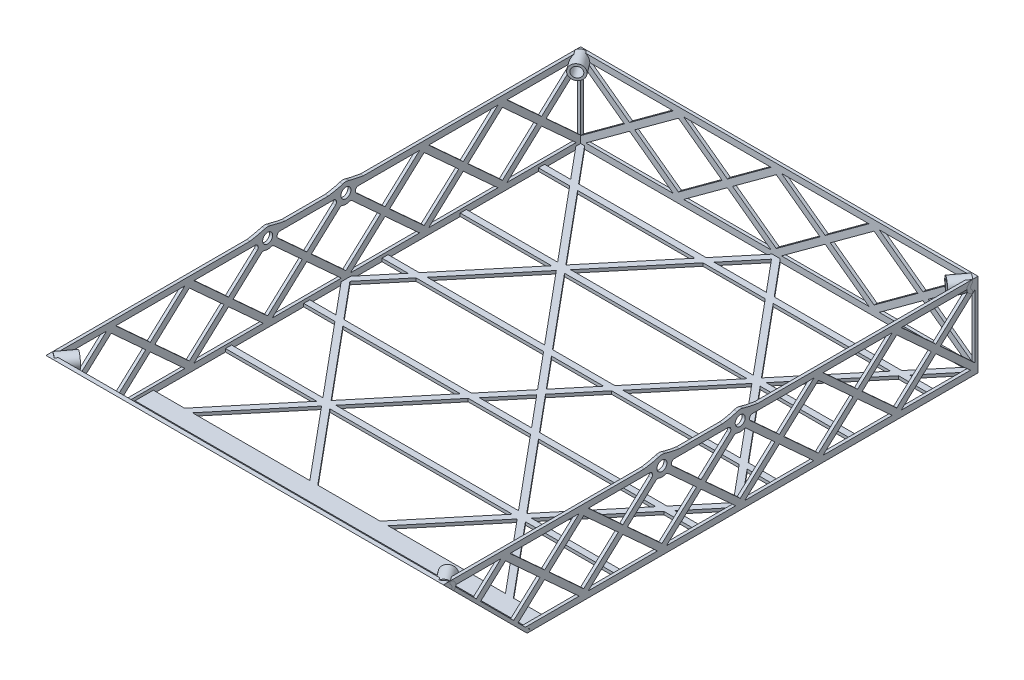
from build123d import *

# Parameters (mm, degrees)
SKETCH1_W                = 206.375
SKETCH1_H                = 233.045
BOSS_EXTRUDE3_DEPTH      = 1.5875
SKETCH2_W                = 206.375
SKETCH2_H                = 247.015
SKETCH2_W_2              = 203.2
SKETCH2_H_2              = 243.84
BOSS_EXTRUDE4_DEPTH      = 41.91
CUT_EXTRUDE3_DEPTH       = 1
CUT_EXTRUDE3_DEPTH_BACK  = 207.375
CUT_EXTRUDE1_DEPTH       = 1
CUT_EXTRUDE1_DEPTH_BACK  = 248.015
BOSS_EXTRUDE5_DEPTH      = 206.375
CUT_EXTRUDE4_DEPTH       = 6.35
CUT_EXTRUDE8_DEPTH       = 1
CUT_EXTRUDE8_DEPTH_BACK  = 207.375
BOSS_EXTRUDE8_DEPTH      = 1.5875
BOSS_EXTRUDE9_DEPTH      = 1.5875
SKETCH18_R               = 5.08
SKETCH18_R_2             = 2.6
BOSS_EXTRUDE10_DEPTH     = 1.5875
SKETCH18_3_R             = 2.6
BOSS_EXTRUDE11_DEPTH     = 1.5875
SKETCH18_4_R             = 2.6
CUT_EXTRUDE9_DEPTH       = 1.5875
SKETCH19_R               = 5.08
SKETCH19_R_2             = 2.6
BOSS_EXTRUDE12_DEPTH     = 1.5875
SKETCH19_4_R             = 2.6
CUT_EXTRUDE10_DEPTH      = 1.5875
FILLET1_R                = 1.5
SKETCH22_R               = 3.81
SKETCH22_R_2             = 2.6
BOSS_EXTRUDE17_DEPTH     = 9.525
CUT_EXTRUDE11_DEPTH      = 2.9050001
CUT_EXTRUDE11_DEPTH_BACK = 44.4975001
CUT_EXTRUDE12_DEPTH      = 228.106352508
CUT_EXTRUDE12_DEPTH_BACK = 2.34703856


with BuildPart() as part:
    # Sketch1 → Boss-Extrude3 (new body)
    with BuildSketch(Plane(origin=(0, 0, 0), x_dir=(1, 0, 0), z_dir=(0, 1, 0))):
        with Locations((0, 6.985)):
            Rectangle(SKETCH1_W, SKETCH1_H)
        Polygon((-101.6, -62.5475), (-54.18937856, -62.5475), (-85.410211893, -100.0125), (-101.6, -100.0125), align=None, mode=Mode.SUBTRACT)
        Polygon((-81.277288107, -100.0125), (-50.8, -63.439754272), (-20.322711893, -100.0125), align=None, mode=Mode.SUBTRACT)
        Polygon((-16.189788107, -100.0125), (-47.41062144, -62.5475), (47.41062144, -62.5475), (16.189788107, -100.0125), align=None, mode=Mode.SUBTRACT)
        Polygon((-85.410211893, -21.9075), (-54.18937856, -59.3725), (-101.6, -59.3725), (-101.6, -21.9075), align=None, mode=Mode.SUBTRACT)
        Polygon((-50.8, -58.480245728), (-81.277288107, -21.9075), (-20.322711893, -21.9075), align=None, mode=Mode.SUBTRACT)
        Polygon((-101.6, -18.7325), (-101.6, -2.479754272), (-88.056045227, -18.7325), align=None, mode=Mode.SUBTRACT)
        Polygon((-101.6, 18.7325), (-88.056045227, 18.7325), (-101.6, 2.479754272), align=None, mode=Mode.SUBTRACT)
        Polygon((-47.41062144, -59.3725), (-16.189788107, -21.9075), (16.189788107, -21.9075), (47.41062144, -59.3725), align=None, mode=Mode.SUBTRACT)
        Polygon((13.543954773, -18.7325), (-13.543954773, -18.7325), (0, -2.479754272), align=None, mode=Mode.SUBTRACT)
        Polygon((-13.543954773, 18.7325), (13.543954773, 18.7325), (0, 2.479754272), align=None, mode=Mode.SUBTRACT)
        Polygon((50.8, -63.439754272), (81.277288107, -100.0125), (20.322711893, -100.0125), align=None, mode=Mode.SUBTRACT)
        Polygon((85.410211893, -100.0125), (54.18937856, -62.5475), (101.6, -62.5475), (101.6, -100.0125), align=None, mode=Mode.SUBTRACT)
        Polygon((50.8, -58.480245728), (20.322711893, -21.9075), (81.277288107, -21.9075), align=None, mode=Mode.SUBTRACT)
        Polygon((17.67687856, -18.7325), (2.066461893, 0), (17.67687856, 18.7325), (83.92312144, 18.7325), (99.533538107, 0), (83.92312144, -18.7325), align=None, mode=Mode.SUBTRACT)
        Polygon((54.18937856, -59.3725), (85.410211893, -21.9075), (101.6, -21.9075), (101.6, -59.3725), align=None, mode=Mode.SUBTRACT)
        Polygon((101.6, -18.7325), (88.056045227, -18.7325), (101.6, -2.479754272), align=None, mode=Mode.SUBTRACT)
        Polygon((101.6, 2.479754272), (88.056045227, 18.7325), (101.6, 18.7325), align=None, mode=Mode.SUBTRACT)
        Polygon((-99.533538107, 0), (-83.92312144, 18.7325), (-17.67687856, 18.7325), (-2.066461893, 0), (-17.67687856, -18.7325), (-83.92312144, -18.7325), align=None, mode=Mode.SUBTRACT)
        Polygon((-81.277288107, 21.9075), (-50.8, 58.480245728), (-20.322711893, 21.9075), align=None, mode=Mode.SUBTRACT)
        Polygon((-54.18937856, 59.3725), (-85.410211893, 21.9075), (-101.6, 21.9075), (-101.6, 59.3725), align=None, mode=Mode.SUBTRACT)
        Polygon((16.189788107, 21.9075), (-16.189788107, 21.9075), (-47.41062144, 59.3725), (47.41062144, 59.3725), align=None, mode=Mode.SUBTRACT)
        Polygon((-85.410211893, 100.0125), (-54.18937856, 62.5475), (-101.6, 62.5475), (-101.6, 100.0125), align=None, mode=Mode.SUBTRACT)
        Polygon((-20.322711893, 100.0125), (-50.8, 63.439754272), (-81.277288107, 100.0125), align=None, mode=Mode.SUBTRACT)
        Polygon((-101.6, 103.1875), (-101.6, 119.440245728), (-88.056045227, 103.1875), align=None, mode=Mode.SUBTRACT)
        Polygon((-17.67687856, 103.1875), (-83.92312144, 103.1875), (-99.533538107, 121.92), (-2.066461893, 121.92), align=None, mode=Mode.SUBTRACT)
        Polygon((47.41062144, 62.5475), (-47.41062144, 62.5475), (-16.189788107, 100.0125), (16.189788107, 100.0125), align=None, mode=Mode.SUBTRACT)
        Polygon((0, 119.440245728), (13.543954773, 103.1875), (-13.543954773, 103.1875), align=None, mode=Mode.SUBTRACT)
        Polygon((50.8, 58.480245728), (81.277288107, 21.9075), (20.322711893, 21.9075), align=None, mode=Mode.SUBTRACT)
        Polygon((101.6, 21.9075), (85.410211893, 21.9075), (54.18937856, 59.3725), (101.6, 59.3725), align=None, mode=Mode.SUBTRACT)
        Polygon((81.277288107, 100.0125), (50.8, 63.439754272), (20.322711893, 100.0125), align=None, mode=Mode.SUBTRACT)
        Polygon((83.92312144, 103.1875), (17.67687856, 103.1875), (2.066461893, 121.92), (99.533538107, 121.92), align=None, mode=Mode.SUBTRACT)
        Polygon((101.6, 100.0125), (101.6, 62.5475), (54.18937856, 62.5475), (85.410211893, 100.0125), align=None, mode=Mode.SUBTRACT)
        Polygon((101.6, 119.440245728), (101.6, 103.1875), (88.056045227, 103.1875), align=None, mode=Mode.SUBTRACT)
    extrude(amount=BOSS_EXTRUDE3_DEPTH)

    # Sketch2 → Boss-Extrude4 (add)
    with BuildSketch(Plane(origin=(0, 1.5875, 0), x_dir=(1, 0, 0), z_dir=(0, 1, 0))):
        Rectangle(SKETCH2_W, SKETCH2_H)
        Rectangle(SKETCH2_W_2, SKETCH2_H_2, mode=Mode.SUBTRACT)
    extrude(amount=BOSS_EXTRUDE4_DEPTH)

    # Sketch4 → Cut-Extrude3 (cut, two sides)
    with BuildSketch(Plane.ZY.offset(103.1875)) as cut_extrude3_sk:
        Polygon((-103.952969238, 21.74875), (-121.92, 38.171739056), (-121.92, 5.325760944), align=None)
        Polygon((-83.632969238, 40.3225), (-119.567030762, 40.3225), (-101.6, 23.899510944), align=None)
        Polygon((-83.632969238, 3.175), (-101.6, 19.597989056), (-119.567030762, 3.175), align=None)
        Polygon((-42.992969238, 40.3225), (-78.927030762, 40.3225), (-60.96, 23.899510944), align=None)
        Polygon((-81.28, 38.171739056), (-99.247030762, 21.74875), (-81.28, 5.325760944), (-63.312969238, 21.74875), align=None)
        Polygon((-60.96, 19.597989056), (-78.927030762, 3.175), (-42.992969238, 3.175), align=None)
        Polygon((-2.352969238, 40.3225), (-38.287030762, 40.3225), (-20.32, 23.899510944), align=None)
        Polygon((-40.64, 38.171739056), (-58.607030762, 21.74875), (-40.64, 5.325760944), (-22.672969238, 21.74875), align=None)
        Polygon((-20.32, 19.597989056), (-38.287030762, 3.175), (-2.352969238, 3.175), align=None)
        Polygon((38.287030762, 40.3225), (2.352969238, 40.3225), (20.32, 23.899510944), align=None)
        Polygon((0, 38.171739056), (-17.967030762, 21.74875), (0, 5.325760944), (17.967030762, 21.74875), align=None)
        Polygon((20.32, 19.597989056), (2.352969238, 3.175), (38.287030762, 3.175), align=None)
        Polygon((78.927030762, 40.3225), (42.992969238, 40.3225), (60.96, 23.899510944), align=None)
        Polygon((40.64, 38.171739056), (22.672969238, 21.74875), (40.64, 5.325760944), (58.607030762, 21.74875), align=None)
        Polygon((60.96, 19.597989056), (42.992969238, 3.175), (78.927030762, 3.175), align=None)
        Polygon((119.567030762, 40.3225), (83.632969238, 40.3225), (101.6, 23.899510944), align=None)
        Polygon((81.28, 38.171739056), (63.312969238, 21.74875), (81.28, 5.325760944), (99.247030762, 21.74875), align=None)
        Polygon((101.6, 19.597989056), (83.632969238, 3.175), (119.567030762, 3.175), align=None)
        Polygon((121.92, 5.325760944), (121.92, 38.171739056), (103.952969238, 21.74875), align=None)
    extrude(amount=CUT_EXTRUDE3_DEPTH, mode=Mode.SUBTRACT)
    extrude(cut_extrude3_sk.sketch, amount=-CUT_EXTRUDE3_DEPTH_BACK, mode=Mode.SUBTRACT)

    # Sketch3 → Cut-Extrude1 (cut, two sides)
    with BuildSketch(Plane.XY.offset(123.5075)) as cut_extrude1_sk:
        Polygon((76.2, 23.715409792), (98.910550711, 40.3225), (53.489449289, 40.3225), align=None)
        Polygon((101.6, 5.141659792), (101.6, 38.355840208), (78.889449289, 21.74875), align=None)
        Polygon((25.4, 23.715409792), (48.110550711, 40.3225), (2.689449289, 40.3225), align=None)
        Polygon((50.8, 5.141659792), (73.510550711, 21.74875), (50.8, 38.355840208), (28.089449289, 21.74875), align=None)
        Polygon((98.910550711, 3.175), (76.2, 19.782090208), (53.489449289, 3.175), align=None)
        Polygon((2.689449289, 3.175), (48.110550711, 3.175), (25.4, 19.782090208), align=None)
        Polygon((-25.4, 23.715409792), (-2.689449289, 40.3225), (-48.110550711, 40.3225), align=None)
        Polygon((0, 5.141659792), (22.710550711, 21.74875), (0, 38.355840208), (-22.710550711, 21.74875), align=None)
        Polygon((-48.110550711, 3.175), (-2.689449289, 3.175), (-25.4, 19.782090208), align=None)
        Polygon((-76.2, 23.715409792), (-53.489449289, 40.3225), (-98.910550711, 40.3225), align=None)
        Polygon((-50.8, 5.141659792), (-28.089449289, 21.74875), (-50.8, 38.355840208), (-73.510550711, 21.74875), align=None)
        Polygon((-98.910550711, 3.175), (-53.489449289, 3.175), (-76.2, 19.782090208), align=None)
        Polygon((-78.889449289, 21.74875), (-101.6, 38.355840208), (-101.6, 5.141659792), align=None)
    extrude(amount=CUT_EXTRUDE1_DEPTH, mode=Mode.SUBTRACT)
    extrude(cut_extrude1_sk.sketch, amount=-CUT_EXTRUDE1_DEPTH_BACK, mode=Mode.SUBTRACT)

    # Sketch7 → Boss-Extrude5 (add)
    with BuildSketch(Plane(origin=(103.1875, 0, 0), x_dir=(0, 0, -1), z_dir=(1, 0, 0))):
        Polygon((-110.674383618, 0), (-108.429319587, 0), (-115.968409784, 7.539090197), (-151.926819587, 43.4975), (-154.171883618, 43.4975), align=None)
    extrude(amount=-BOSS_EXTRUDE5_DEPTH)

    # Sketch8 → Cut-Extrude4 (cut)
    with BuildSketch(Plane(origin=(0, -55.337191809, 55.337191809), x_dir=(1, 0, 0), z_dir=(0, -0.707106781, 0.707106781))):
        Polygon((-76.770919233, 136.598361589), (-98.250955767, 136.598361589), (-87.5109375, 114.266316603), align=None)
        Polygon((-89.272481733, 110.603484374), (-100.0125, 132.93552936), (-100.0125, 88.271439388), align=None)
        Polygon((-76.770919233, 84.60860716), (-87.5109375, 106.940652146), (-98.250955767, 84.60860716), align=None)
        Polygon((-75.009375, 132.93552936), (-85.749393267, 110.603484374), (-75.009375, 88.271439388), (-64.269356733, 110.603484374), align=None)
        Polygon((-62.5078125, 106.940652146), (-73.247830767, 84.60860716), (-51.767794233, 84.60860716), align=None)
        Polygon((-50.00625, 132.93552936), (-60.746268267, 110.603484374), (-50.00625, 88.271439388), (-39.266231733, 110.603484374), align=None)
        Polygon((-37.5046875, 106.940652146), (-48.244705767, 84.60860716), (-26.764669233, 84.60860716), align=None)
        Polygon((-25.003125, 132.93552936), (-35.743143267, 110.603484374), (-25.003125, 88.271439388), (-14.263106733, 110.603484374), align=None)
        Polygon((-12.5015625, 106.940652146), (-23.241580767, 84.60860716), (-1.761544233, 84.60860716), align=None)
        Polygon((0, 132.93552936), (-10.740018267, 110.603484374), (0, 88.271439388), (10.740018267, 110.603484374), align=None)
        Polygon((12.5015625, 106.940652146), (1.761544233, 84.60860716), (23.241580767, 84.60860716), align=None)
        Polygon((25.003125, 132.93552936), (14.263106733, 110.603484374), (25.003125, 88.271439388), (35.743143267, 110.603484374), align=None)
        Polygon((37.5046875, 106.940652146), (26.764669233, 84.60860716), (48.244705767, 84.60860716), align=None)
        Polygon((50.00625, 132.93552936), (39.266231733, 110.603484374), (50.00625, 88.271439388), (60.746268267, 110.603484374), align=None)
        Polygon((62.5078125, 106.940652146), (51.767794233, 84.60860716), (73.247830767, 84.60860716), align=None)
        Polygon((75.009375, 132.93552936), (64.269356733, 110.603484374), (75.009375, 88.271439388), (85.749393267, 110.603484374), align=None)
        Polygon((87.5109375, 106.940652146), (76.770919233, 84.60860716), (98.250955767, 84.60860716), align=None)
        Polygon((100.0125, 132.93552936), (89.272481733, 110.603484374), (100.0125, 88.271439388), align=None)
        Polygon((98.250955767, 136.598361589), (76.770919233, 136.598361589), (87.5109375, 114.266316603), align=None)
        Polygon((73.247830767, 136.598361589), (51.767794233, 136.598361589), (62.5078125, 114.266316603), align=None)
        Polygon((48.244705767, 136.598361589), (26.764669233, 136.598361589), (37.5046875, 114.266316603), align=None)
        Polygon((23.241580767, 136.598361589), (1.761544233, 136.598361589), (12.5015625, 114.266316603), align=None)
        Polygon((-1.761544233, 136.598361589), (-23.241580767, 136.598361589), (-12.5015625, 114.266316603), align=None)
        Polygon((-26.764669233, 136.598361589), (-48.244705767, 136.598361589), (-37.5046875, 114.266316603), align=None)
        Polygon((-51.767794233, 136.598361589), (-73.247830767, 136.598361589), (-62.5078125, 114.266316603), align=None)
    extrude(amount=-CUT_EXTRUDE4_DEPTH, mode=Mode.SUBTRACT)

    # Sketch14 → Cut-Extrude8 (cut, two sides)
    with BuildSketch(Plane(origin=(103.1875, 0, 0), x_dir=(0, 0, -1), z_dir=(1, 0, 0))) as cut_extrude8_sk:
        Polygon((-121.92, 13.490680413), (-123.5075, 15.078180413), (-123.5075, 43.4975), (-121.92, 43.4975), (-121.92, 38.171739056), align=None)
        Polygon((-121.92, 11.245616382), (-123.5075, 12.833116382), (-123.5075, 1.5875), (-121.92, 1.5875), (-112.261883618, 1.5875), (-113.849383618, 3.175), (-119.567030762, 3.175), (-116.579851846, 5.905468228), (-118.827177567, 8.152793949), (-121.92, 5.325760944), align=None)
    extrude(amount=CUT_EXTRUDE8_DEPTH, mode=Mode.SUBTRACT)
    extrude(cut_extrude8_sk.sketch, amount=-CUT_EXTRUDE8_DEPTH_BACK, mode=Mode.SUBTRACT)

    # Sketch15 → Boss-Extrude8 (add)
    with BuildSketch(Plane(origin=(103.1875, 0, 0), x_dir=(0, 0, -1), z_dir=(1, 0, 0))):
        Polygon((-121.92, 43.4975), (-151.926819587, 43.4975), (-148.751819587, 40.3225), (-124.272969238, 40.3225), (-137.061919625, 28.632600037), (-134.814593903, 26.385274316), (-121.92, 38.171739056), align=None)
    extrude(amount=-BOSS_EXTRUDE8_DEPTH)

    # Sketch16 → Boss-Extrude9 (add)
    with BuildSketch(Plane.ZY.offset(103.1875)):
        Polygon((151.926819587, 43.4975), (121.92, 43.4975), (121.92, 38.171739056), (134.814593903, 26.385274316), (137.061919625, 28.632600037), (124.272969238, 40.3225), (148.751819587, 40.3225), align=None)
    extrude(amount=-BOSS_EXTRUDE9_DEPTH)

    # Sketch18 → Boss-Extrude10 (add)
    with BuildSketch(Plane(origin=(103.1875, 0, 0), x_dir=(0, 0, -1), z_dir=(1, 0, 0))):
        with BuildLine():
            add(Edge.make_bspline(
                [(-1.614436912, 45.139137152), (-5.499501722, 43.836943975), (-9.111138785, 43.4975)],
                knots=[0, 0, 0, 1, 1, 1], degree=2))
            Line((-9.111138785, 43.4975), (-3.965573729, 43.4975))
            ThreePointArc((-3.965573729, 43.4975), (-2.908242222, 44.487656321), (-1.614436912, 45.139137152))
        make_face()
        with BuildLine():
            add(Edge.make_bspline(
                [(1.614436912, 45.139137152), (4.142208705, 44.291880454), (9.120643035, 43.4975)],
                knots=[0, 0, 0, 1, 1, 1], degree=2))
            ThreePointArc((1.614436912, 45.139137152), (2.908242222, 44.487656321), (3.965573729, 43.4975))
            Line((3.965573729, 43.4975), (9.120643035, 43.4975))
        make_face()
        with Locations((0, 40.3225)):
            Circle(SKETCH18_R)
        with Locations((0, 40.3225)):
            Circle(SKETCH18_R_2, mode=Mode.SUBTRACT)
    extrude(amount=-BOSS_EXTRUDE10_DEPTH)

    # Sketch18_3 → Boss-Extrude11 (add)
    with BuildSketch(Plane(origin=(103.1875, 0, 0), x_dir=(0, 0, -1), z_dir=(1, 0, 0))):
        with BuildLine():
            add(Edge.make_bspline(
                [(-42.254436912, 45.139137152), (-44.782208705, 44.291880454), (-49.760643035, 43.4975)],
                knots=[0, 0, 0, 1, 1, 1], degree=2))
            Line((-49.760643035, 43.4975), (-44.605573729, 43.4975))
            ThreePointArc((-44.605573729, 43.4975), (-40.64, 35.2425), (-36.674426271, 43.4975))
            Line((-36.674426271, 43.4975), (-31.521028638, 43.4975))
            add(Edge.make_bspline(
                [(-39.025563088, 45.139137152), (-36.199402945, 44.191866866), (-31.521028638, 43.4975)],
                knots=[0, 0, 0, 1, 1, 1], degree=2))
            ThreePointArc((-39.025563088, 45.139137152), (-40.64, 45.4025), (-42.254436912, 45.139137152))
        make_face()
        with Locations((-40.64, 40.3225)):
            Circle(SKETCH18_3_R, mode=Mode.SUBTRACT)
    extrude(amount=-BOSS_EXTRUDE11_DEPTH)

    # Sketch18_4 → Cut-Extrude9 (cut)
    with BuildSketch(Plane(origin=(103.1875, 0, 0), x_dir=(0, 0, -1), z_dir=(1, 0, 0))):
        with Locations((-40.64, 40.3225)):
            Circle(SKETCH18_4_R)
        with Locations((0, 40.3225)):
            Circle(SKETCH18_4_R)
    extrude(amount=-CUT_EXTRUDE9_DEPTH, mode=Mode.SUBTRACT)

    # Sketch19 → Boss-Extrude12 (add)
    with BuildSketch(Plane.ZY.offset(103.1875)):
        with BuildLine():
            add(Edge.make_bspline(
                [(1.614284382, 45.139188278), (4.374956015, 44.213965626), (9.111138785, 43.4975)],
                knots=[0, 0, 0, 1, 1, 1], degree=2))
            ThreePointArc((1.614284381, 45.139188275), (2.908176272, 44.487702369), (3.965573729, 43.4975))
            Line((3.965573729, 43.4975), (9.111138785, 43.4975))
        make_face()
        with BuildLine():
            add(Edge.make_bspline(
                [(-1.614629048, 45.139072754), (-3.230703048, 44.597326546), (-9.111138785, 43.4975)],
                knots=[0, 0, 0, 1, 1, 1], degree=2))
            Line((-9.111138785, 43.4975), (-3.965573729, 43.4975))
            ThreePointArc((-3.965573729, 43.4975), (-2.908325296, 44.487598315), (-1.614629046, 45.139072749))
        make_face()
        with BuildLine():
            ThreePointArc((36.674426271, 43.4975), (37.87431761, 44.583650187), (39.354937699, 45.237275161))
            add(Edge.make_bspline(
                [(39.354937699, 45.237275161), (32.730253067, 43.505124208), (31.528861215, 43.4975)],
                knots=[0, 0, 0, 1, 1, 1], degree=2))
            Line((31.528861215, 43.4975), (36.674426271, 43.4975))
        make_face()
        with BuildLine():
            Line((44.605573729, 43.4975), (49.751138785, 43.4975))
            add(Edge.make_bspline(
                [(41.925062301, 45.237275161), (46.233476635, 44.110757537), (49.751138785, 43.4975)],
                knots=[0, 0, 0, 1, 1, 1], degree=2))
            ThreePointArc((41.925062301, 45.237275161), (43.40568239, 44.583650187), (44.605573729, 43.4975))
        make_face()
        with Locations((40.64, 40.3225)):
            Circle(SKETCH19_R)
        with Locations((40.64, 40.3225)):
            Circle(SKETCH19_R_2, mode=Mode.SUBTRACT)
        with Locations((0, 40.3225)):
            Circle(SKETCH19_R)
        with Locations((0, 40.3225)):
            Circle(SKETCH19_R_2, mode=Mode.SUBTRACT)
    extrude(amount=-BOSS_EXTRUDE12_DEPTH)

    # Sketch19_4 → Cut-Extrude10 (cut)
    with BuildSketch(Plane.ZY.offset(103.1875)):
        with Locations((0, 40.3225)):
            Circle(SKETCH19_4_R)
        with Locations((40.64, 40.3225)):
            Circle(SKETCH19_4_R)
    extrude(amount=-CUT_EXTRUDE10_DEPTH, mode=Mode.SUBTRACT)

    # Fillet1
    fillet1_edges = [part.edges().sort_by_distance(p)[0] for p in [
        (102.39375, 40.3225, 5.08),
        (102.39375, 40.3225, -5.08),
        (102.39375, 38.238529808, 4.632868252),
        (102.39375, 38.238529808, -4.632868252),
        (102.39375, 35.895027842, 2.490760986),
        (102.39375, 35.895027842, -2.490760986),
        (102.39375, 40.3225, 35.56),
        (102.39375, 40.3225, 45.72),
        (102.39375, 38.238529808, 45.272868252),
        (102.39375, 38.238529808, 36.007131748),
        (102.39375, 35.895027842, 43.130760986),
        (102.39375, 35.895027842, 38.149239014),
        (-102.39375, 38.238529808, 36.007131748),
        (-102.39375, 40.3225, 45.72),
        (-102.39375, 38.238529808, 45.272868252),
        (-102.39375, 40.3225, 35.56),
        (-102.39375, 35.895027842, 38.149239014),
        (-102.39375, 35.895027842, 43.130760986),
        (-102.39375, 38.238529808, 4.632868252),
        (-102.39375, 40.3225, -5.08),
        (-102.39375, 38.238529808, -4.632868252),
        (-102.39375, 40.3225, 5.08),
        (-102.39375, 35.895027842, -2.490760986),
        (-102.39375, 35.895027842, 2.490760986),
    ]]
    fillet(fillet1_edges, radius=FILLET1_R)


with BuildPart() as body_2:
    # Sketch22 → Boss-Extrude17 (new body)
    with BuildSketch(Plane(origin=(101.6, 43.4975, -121.92), x_dir=(-0.803065292, 0, -0.595891044), z_dir=(0.595891044, 0, -0.803065292))):
        with Locations((0, -3.175)):
            Circle(SKETCH22_R)
        with Locations((0, -3.175)):
            Circle(SKETCH22_R_2, mode=Mode.SUBTRACT)
    extrude(amount=-BOSS_EXTRUDE17_DEPTH)

    # Sketch23 → Cut-Extrude11 (cut, two sides)
    with BuildSketch(Plane(origin=(0, 43.4975, 0), x_dir=(1, 0, 0), z_dir=(0, 1, 0))) as cut_extrude11_sk:
        Polygon((103.1875, 117.255050864), (106.333700827, 120.139374056), (103.1875, 121.92), align=None)
        Polygon((97.615671329, 123.5075), (100.716860927, 123.5075), (97.922632627, 126.3017283), align=None)
    extrude(amount=CUT_EXTRUDE11_DEPTH, mode=Mode.SUBTRACT)
    extrude(cut_extrude11_sk.sketch, amount=-CUT_EXTRUDE11_DEPTH_BACK, mode=Mode.SUBTRACT)


with BuildPart() as body_3:
    # Mirror8: mirrored copy
    add(body_2.part.mirror(Plane.ZY))


with BuildPart() as body_4:
    # Mirror9: mirrored copy
    add(body_3.part.mirror(Plane.XY.offset(15.003409794)))


with BuildPart() as body_5:
    # Mirror9 2: mirrored copy
    add(body_2.part.mirror(Plane.XY.offset(15.003409794)))


with BuildPart() as cut_extrude12_tool:
    # Sketch24 → Cut-Extrude12 (new body, two sides)
    with BuildSketch(Plane(origin=(0, 98.834691809, 98.834691809), x_dir=(1, 0, 0), z_dir=(0, -0.707106781, -0.707106781))) as cut_extrude12_sk:
        Polygon((-94.694626648, 78.25860716), (-106.131638332, 78.25860716), (-105.013352745, 83.500843787), (-96.600795262, 83.72958402), align=None)
        Polygon((91.451632527, 78.25860716), (98.805817694, 88.226938127), (110.950729197, 84.276690095), (107.756911639, 77.594887572), (103.1875, 78.25860716), align=None)
    extrude(amount=CUT_EXTRUDE12_DEPTH)
    extrude(cut_extrude12_sk.sketch, amount=-CUT_EXTRUDE12_DEPTH_BACK)


with BuildPart() as body_4_1:
    add(body_4.part)

    # Cut-Extrude12: cut by cut_extrude12_tool
    add(cut_extrude12_tool.part, mode=Mode.SUBTRACT)


with BuildPart() as body_5_1:
    add(body_5.part)

    # Cut-Extrude12: cut by cut_extrude12_tool
    add(cut_extrude12_tool.part, mode=Mode.SUBTRACT)


solid = Compound([part.part, body_2.part, body_3.part, body_4_1.part, body_5_1.part])
